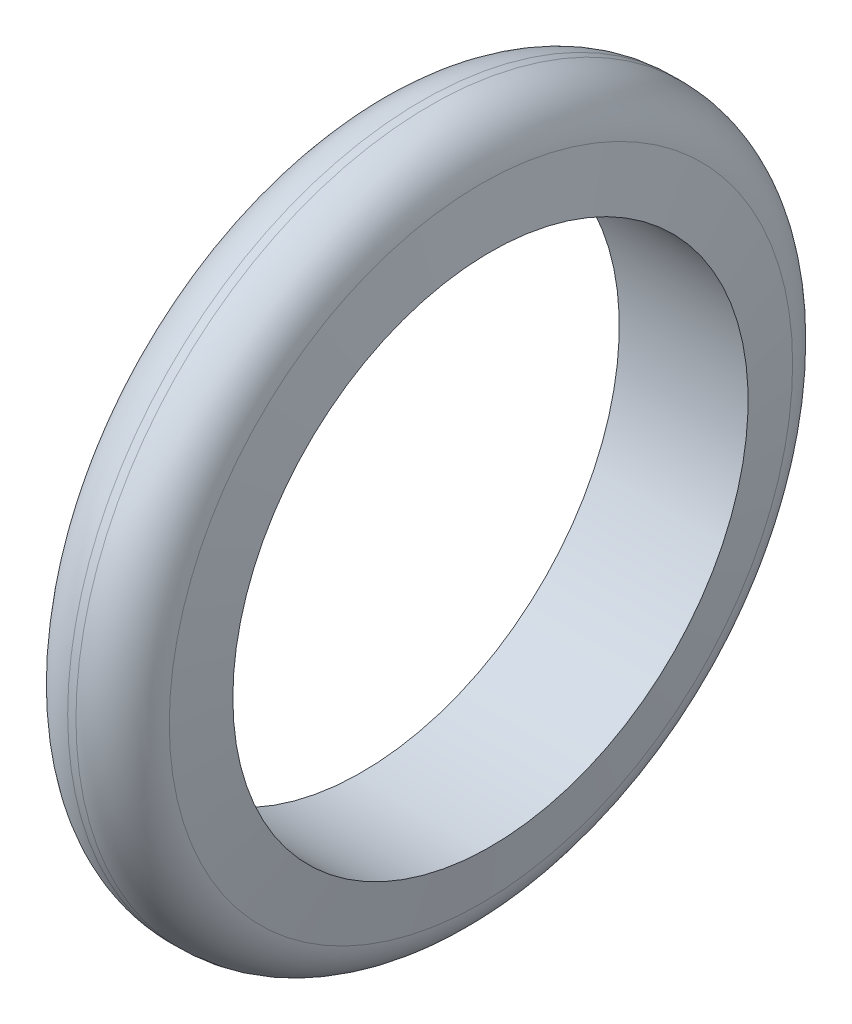
from build123d import *

# Parameters (mm, degrees)
FILLET1_R = 8
FILLET2_R = 8


with BuildPart() as part:
    # Sketch1 → Revolve1 (revolve)
    with BuildSketch(Plane.XY):
        Polygon((-10, 40), (10, 40), (7.355095289, 55), (-7.355095289, 55), align=None)
    revolve(axis=Axis((0, 0, 0), (1, 0, 0)))

    # Fillet1
    fillet1_edges = [part.edges().sort_by_distance(p)[0] for p in [
        (7.355095289, -55, 0),
    ]]
    fillet(fillet1_edges, radius=FILLET1_R)

    # Fillet2
    fillet2_edges = [part.edges().sort_by_distance(p)[0] for p in [
        (-7.355095289, -55, 0),
    ]]
    fillet(fillet2_edges, radius=FILLET2_R)


solid = part.part
